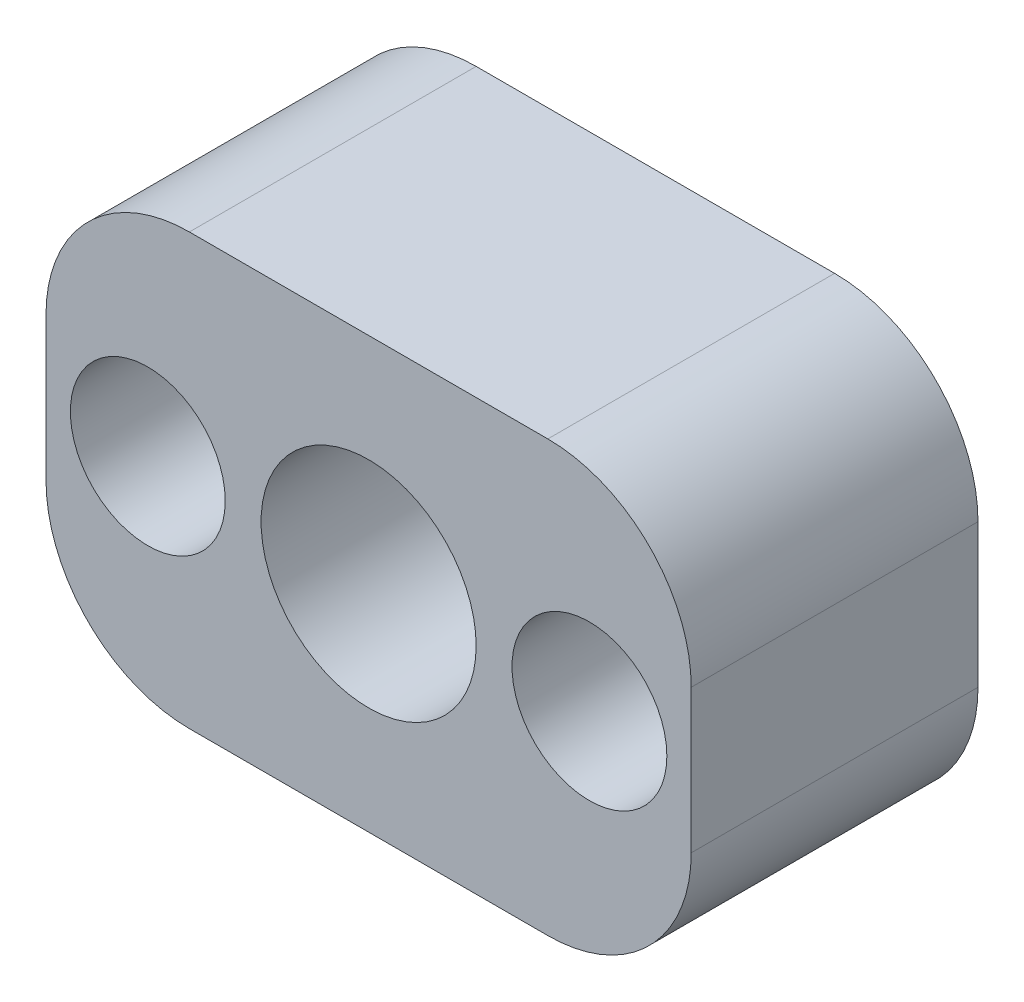
from build123d import *

# Parameters (mm, degrees)
BOSS_EXTRUDE1_DEPTH = 12.7
FILLET1_R           = 6.35
SKETCH2_R           = 3.429
CUT_EXTRUDE1_DEPTH  = 6.35


with BuildPart() as part:
    # Sketch1 → Boss-Extrude1 (new body)
    with BuildSketch(Plane.XY):
        with BuildLine():
            Line((-14.2875, -4.7625), (-14.2875, 0))
            Line((-14.2875, 0), (-28.575, 0))
            Line((-28.575, 0), (-28.575, -9.525))
            Line((-28.575, -9.525), (-25.9715, -9.525))
            ThreePointArc((-25.9715, -9.525), (-24.0665, -7.62), (-22.1615, -9.525))
            Line((-22.1615, -9.525), (-19.05, -9.525))
            ThreePointArc((-19.05, -9.525), (-17.655096045, -6.157403955), (-14.2875, -4.7625))
        make_face()
        with BuildLine():
            ThreePointArc((-14.2875, -14.2875), (-17.655096045, -12.892596045), (-19.05, -9.525))
            Line((-19.05, -9.525), (-22.1615, -9.525))
            ThreePointArc((-22.1615, -9.525), (-24.0665, -11.43), (-25.9715, -9.525))
            Line((-25.9715, -9.525), (-28.575, -9.525))
            Line((-28.575, -9.525), (-28.575, -19.05))
            Line((-28.575, -19.05), (-14.2875, -19.05))
            Line((-14.2875, -19.05), (-14.2875, -14.2875))
        make_face()
        with BuildLine():
            Line((-6.4135, -9.525), (-9.525, -9.525))
            ThreePointArc((-9.525, -9.525), (-10.919903955, -12.892596045), (-14.2875, -14.2875))
            Line((-14.2875, -14.2875), (-14.2875, -19.05))
            Line((-14.2875, -19.05), (0, -19.05))
            Line((0, -19.05), (0, -9.525))
            Line((0, -9.525), (-2.6035, -9.525))
            ThreePointArc((-2.6035, -9.525), (-4.5085, -11.43), (-6.4135, -9.525))
        make_face()
        with BuildLine():
            Line((0, 0), (-14.2875, 0))
            Line((-14.2875, 0), (-14.2875, -4.7625))
            ThreePointArc((-14.2875, -4.7625), (-10.919903955, -6.157403955), (-9.525, -9.525))
            Line((-9.525, -9.525), (-6.4135, -9.525))
            ThreePointArc((-6.4135, -9.525), (-4.5085, -7.62), (-2.6035, -9.525))
            Line((-2.6035, -9.525), (0, -9.525))
            Line((0, -9.525), (0, 0))
        make_face()
    extrude(amount=BOSS_EXTRUDE1_DEPTH)

    # Fillet1
    fillet1_edges = [part.edges().sort_by_distance(p)[0] for p in [
        (-28.575, -19.05, 6.35),
        (-28.575, 0, 6.35),
        (0, 0, 6.35),
        (0, -19.05, 6.35),
    ]]
    fillet(fillet1_edges, radius=FILLET1_R)

    # Sketch2 → Cut-Extrude1 (cut)
    with BuildSketch(Plane.XY.offset(12.7)):
        with Locations((-24.0665, -9.525)):
            Circle(SKETCH2_R)
        with Locations((-4.5085, -9.525)):
            Circle(SKETCH2_R)
    extrude(amount=-CUT_EXTRUDE1_DEPTH, mode=Mode.SUBTRACT)


solid = part.part
